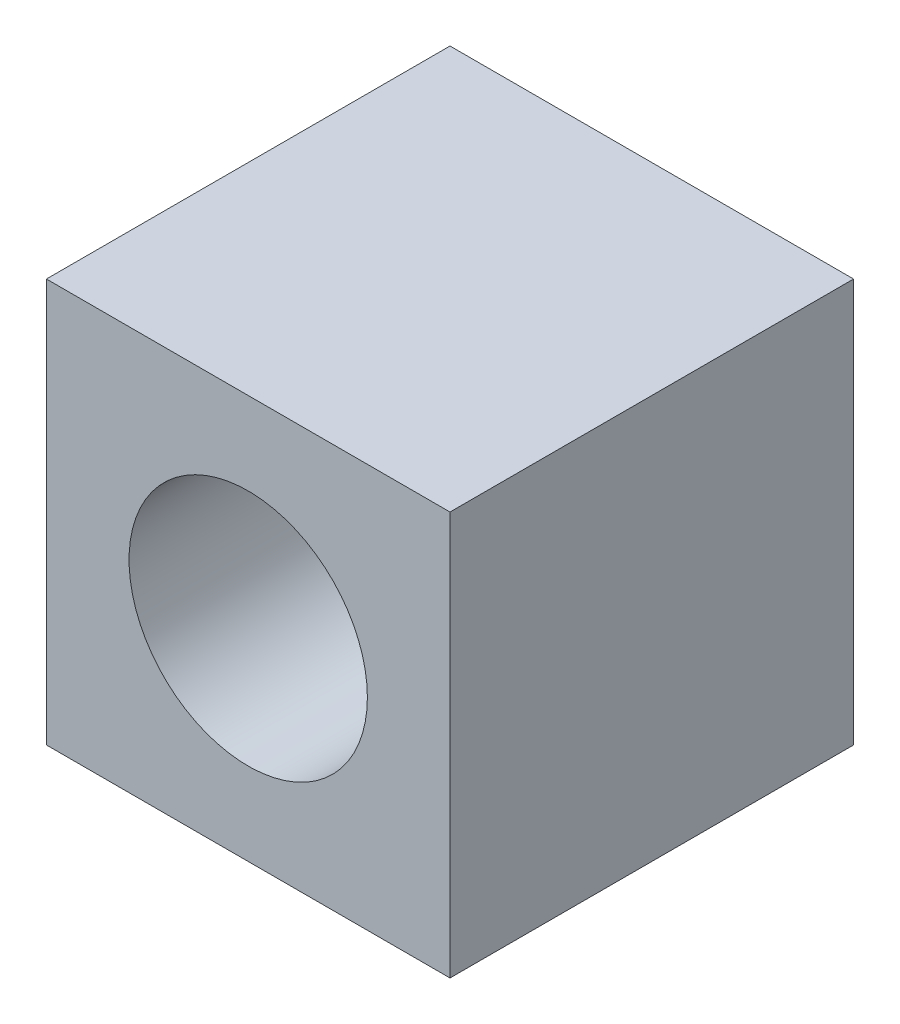
from build123d import *

# Parameters (mm, degrees)
SKETCH1_W           = 50.8
SKETCH1_H           = 50.8
BOSS_EXTRUDE1_DEPTH = 50.8
SKETCH2_R           = 15
CUT_EXTRUDE1_DEPTH  = 50.8


with BuildPart() as part:
    # Sketch1 → Boss-Extrude1 (new body)
    with BuildSketch(Plane.XY):
        Rectangle(SKETCH1_W, SKETCH1_H)
    extrude(amount=BOSS_EXTRUDE1_DEPTH)

    # Sketch2 → Cut-Extrude1 (cut)
    with BuildSketch(Plane.XY.offset(50.8)):
        Circle(SKETCH2_R)
    extrude(amount=-CUT_EXTRUDE1_DEPTH, mode=Mode.SUBTRACT)


solid = part.part
